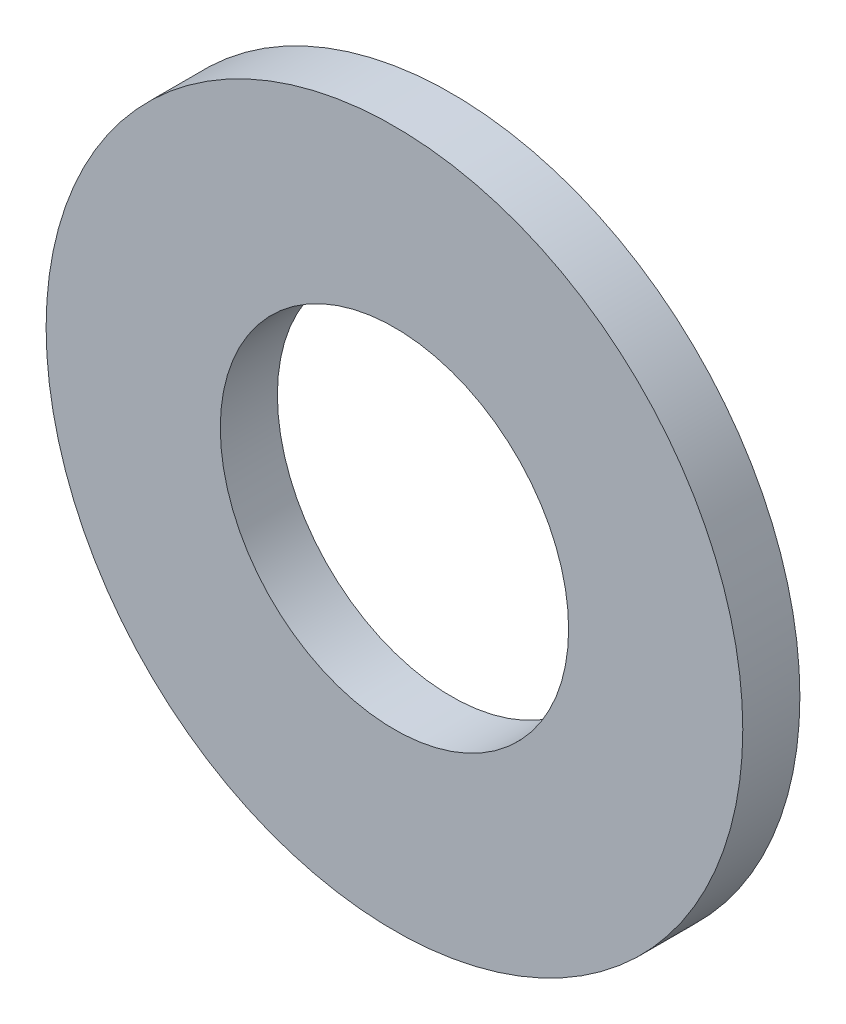
from build123d import *

# Parameters (mm, degrees)
SKETCH1_R           = 6.1
SKETCH1_R_2         = 3.05
BOSS_EXTRUDE1_DEPTH = 1


with BuildPart() as part:
    # Sketch1 → Boss-Extrude1 (new body)
    with BuildSketch(Plane.XY):
        Circle(SKETCH1_R)
        Circle(SKETCH1_R_2, mode=Mode.SUBTRACT)
    extrude(amount=BOSS_EXTRUDE1_DEPTH)


solid = part.part
